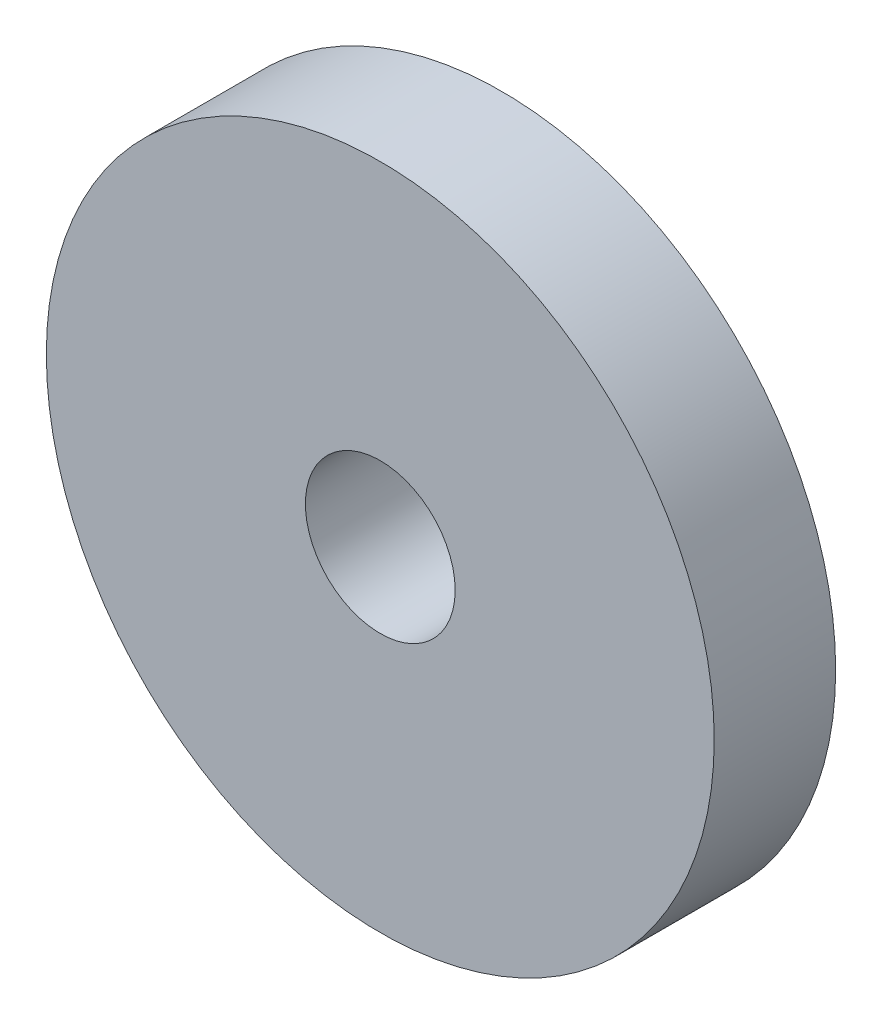
from build123d import *

# Parameters (mm, degrees)
SKIZZE1_R                       = 8.25
SKIZZE1_R_2                     = 1.85
AUFSATZ_LINEAR_AUSTRAGEN1_DEPTH = 3


with BuildPart() as part:
    # Skizze1 → Aufsatz-Linear austragen1 (new body)
    with BuildSketch(Plane.XY):
        Circle(SKIZZE1_R)
        Circle(SKIZZE1_R_2, mode=Mode.SUBTRACT)
    extrude(amount=AUFSATZ_LINEAR_AUSTRAGEN1_DEPTH)


solid = part.part
